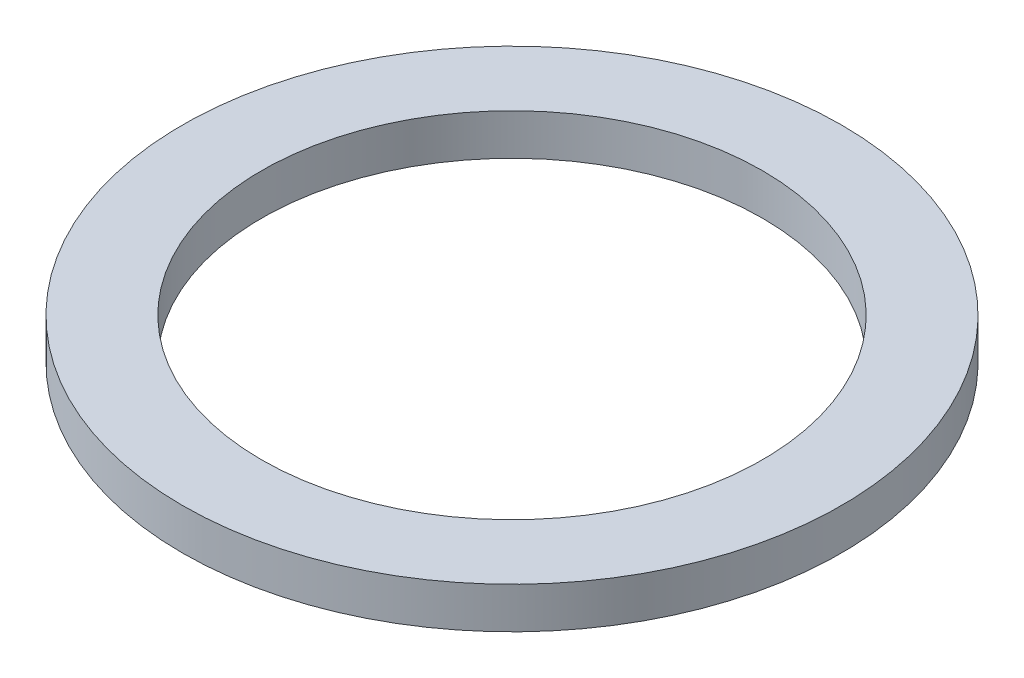
from build123d import *

# Parameters (mm, degrees)
SKETCH1_R           = 12.7
SKETCH1_R_2         = 9.652
BOSS_EXTRUDE1_DEPTH = 1.5875


with BuildPart() as part:
    # Sketch1 → Boss-Extrude1 (new body)
    with BuildSketch(Plane(origin=(0, 0, 0), x_dir=(1, 0, 0), z_dir=(0, 1, 0))):
        Circle(SKETCH1_R)
        Circle(SKETCH1_R_2, mode=Mode.SUBTRACT)
    extrude(amount=BOSS_EXTRUDE1_DEPTH)


solid = part.part
